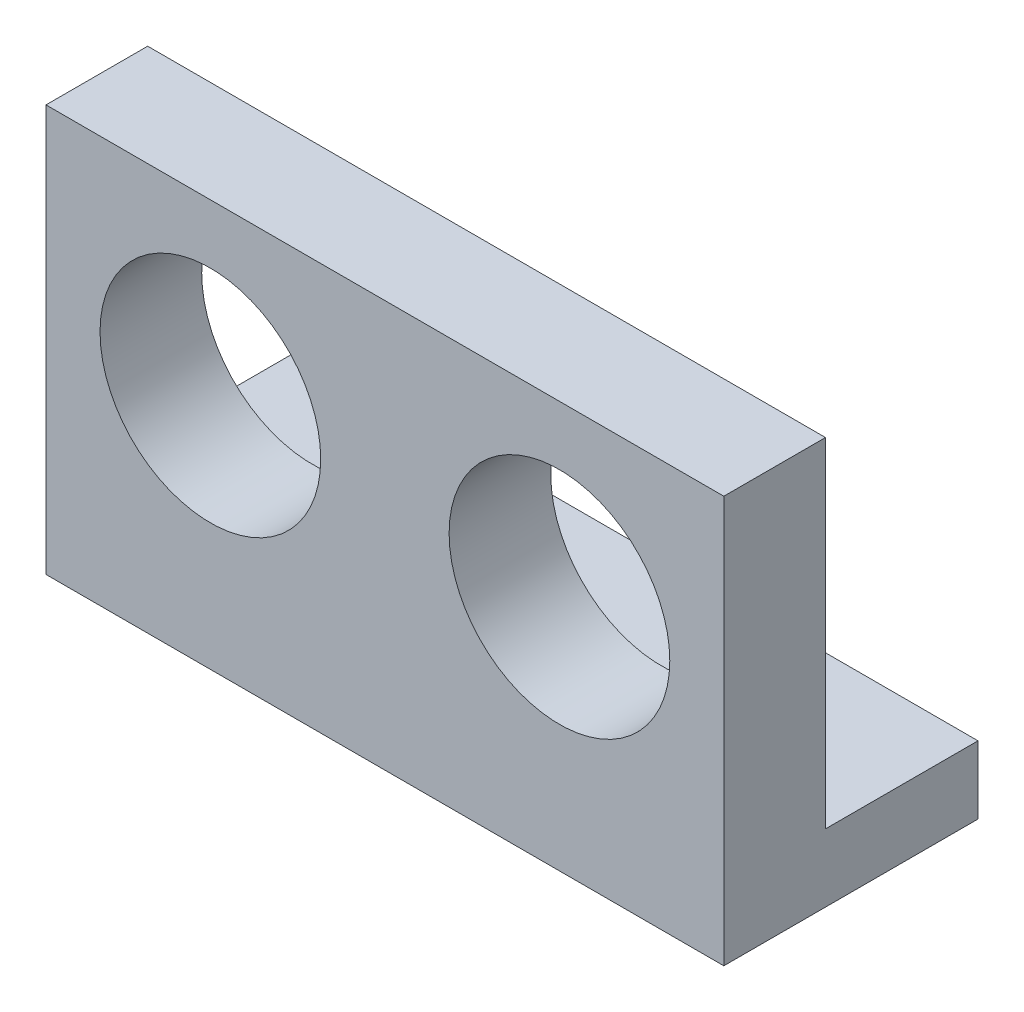
from build123d import *

# Parameters (mm, degrees)
SKETCH12_W          = 50.8
SKETCH12_H          = 25.4
BOSS_EXTRUDE1_DEPTH = 7.62
SKETCH11_R          = 8.2696685
CUT_EXTRUDE2_DEPTH  = 8.62
SKETCH14_W          = 50.8
SKETCH14_H          = 19.05
BOSS_EXTRUDE2_DEPTH = 5.08


with BuildPart() as part:
    # Sketch12 → Boss-Extrude1 (new body)
    with BuildSketch(Plane.XY):
        with Locations((0, 12.7)):
            Rectangle(SKETCH12_W, SKETCH12_H)
    extrude(amount=BOSS_EXTRUDE1_DEPTH)

    # Sketch11 → Cut-Extrude2 (cut, through all)
    with BuildSketch(Plane.XY):
        with Locations((13.081, 12.7)):
            Circle(SKETCH11_R)
        with Locations((-13.081, 12.7)):
            Circle(SKETCH11_R)
    extrude(amount=CUT_EXTRUDE2_DEPTH, mode=Mode.SUBTRACT)

    # Sketch14 → Boss-Extrude2 (add)
    with BuildSketch(Plane(origin=(0, 0, 0), x_dir=(-1, 0, 0), z_dir=(0, -1, 0))):
        with Locations((0, 1.905)):
            Rectangle(SKETCH14_W, SKETCH14_H)
    extrude(amount=BOSS_EXTRUDE2_DEPTH)


solid = part.part
